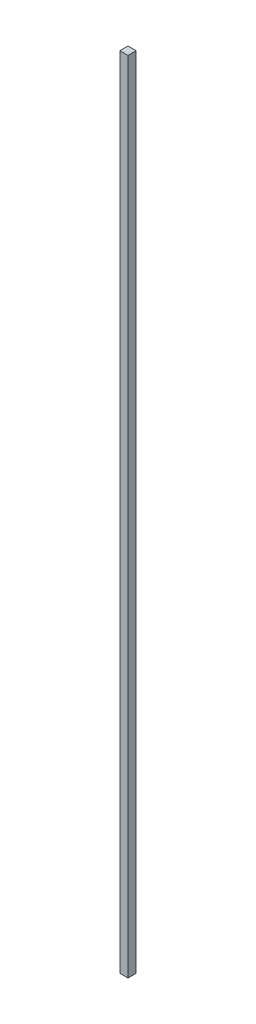
from build123d import *

# Parameters (mm, degrees)
SKETCH1_W           = 20
SKETCH1_H           = 20
BOSS_EXTRUDE1_DEPTH = 1960


with BuildPart() as part:
    # Sketch1 → Boss-Extrude1 (new body)
    with BuildSketch(Plane(origin=(0, 0, 0), x_dir=(1, 0, 0), z_dir=(0, 1, 0))):
        with Locations((10, -10)):
            Rectangle(SKETCH1_W, SKETCH1_H)
    extrude(amount=BOSS_EXTRUDE1_DEPTH)


solid = part.part
